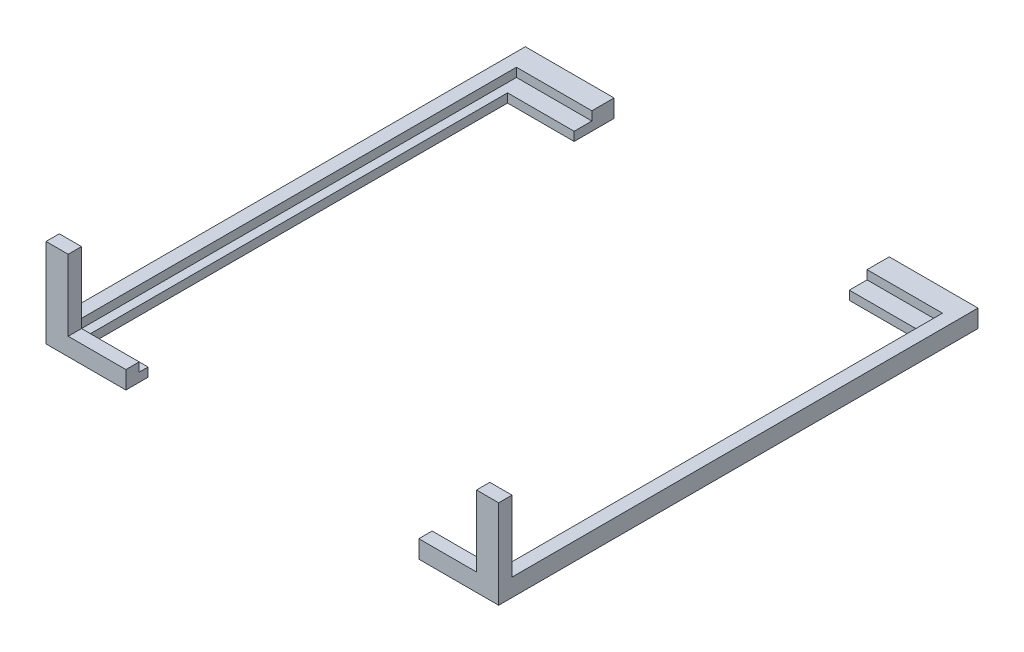
from build123d import *

# Parameters (mm, degrees)
SKETCH_1_W          = 51
SKETCH_1_H          = 54
EXTRUDE_1_DEPTH     = 10
SKETCH_2_W          = 46
SKETCH_2_H          = 47
CUT_EXTRUDE_1_DEPTH = 11
SKETCH_3_W          = 48
SKETCH_3_H          = 50
CUT_EXTRUDE_2_DEPTH = 9
SKETCH_4_W          = 31
SKETCH_4_H          = 4.5
CUT_EXTRUDE_3_DEPTH = 11
SKETCH_5_W          = 48
SKETCH_5_H          = 4.5
CUT_EXTRUDE_4_DEPTH = 8
SKETCH_6_W          = 1.5
SKETCH_6_H          = 52.5
CUT_EXTRUDE_5_DEPTH = 8
SKETCH_7_W          = 46
SKETCH_7_H          = 1.5
CUT_EXTRUDE_6_DEPTH = 8
SKETCH_8_W          = 33
SKETCH_8_H          = 5
CUT_EXTRUDE_7_DEPTH = 3


with BuildPart() as part:
    # 草图1 → 凸台-拉伸1 (new body)
    with BuildSketch(Plane(origin=(0, 0, 0), x_dir=(1, 0, 0), z_dir=(0, 1, 0))):
        Rectangle(SKETCH_1_W, SKETCH_1_H)
    extrude(amount=EXTRUDE_1_DEPTH)

    # 草图2 → 切除-拉伸1 (cut, through all)
    with BuildSketch(Plane(origin=(0, 10, 0), x_dir=(1, 0, 0), z_dir=(0, 1, 0))):
        with Locations((0, -1)):
            Rectangle(SKETCH_2_W, SKETCH_2_H)
    extrude(amount=-CUT_EXTRUDE_1_DEPTH, mode=Mode.SUBTRACT)

    # 草图3 → 切除-拉伸2 (cut)
    with BuildSketch(Plane(origin=(0, 10, 0), x_dir=(1, 0, 0), z_dir=(0, 1, 0))):
        with Locations((0, -0.5)):
            Rectangle(SKETCH_3_W, SKETCH_3_H)
    extrude(amount=-CUT_EXTRUDE_2_DEPTH, mode=Mode.SUBTRACT)

    # 草图4 → 切除-拉伸3 (cut, through all)
    with BuildSketch(Plane(origin=(0, 10, 0), x_dir=(1, 0, 0), z_dir=(0, 1, 0))):
        with Locations((0, 24.75)):
            Rectangle(SKETCH_4_W, SKETCH_4_H)
    extrude(amount=-CUT_EXTRUDE_3_DEPTH, mode=Mode.SUBTRACT)

    # 草图5 → 切除-拉伸4 (cut)
    with BuildSketch(Plane(origin=(0, 10, 0), x_dir=(1, 0, 0), z_dir=(0, 1, 0))):
        with Locations((0, 24.75)):
            Rectangle(SKETCH_5_W, SKETCH_5_H)
    extrude(amount=-CUT_EXTRUDE_4_DEPTH, mode=Mode.SUBTRACT)

    # 草图6 → 切除-拉伸5 (cut)
    with BuildSketch(Plane(origin=(0, 10, 0), x_dir=(1, 0, 0), z_dir=(0, 1, 0))):
        with Locations((-24.75, 0.75)):
            Rectangle(SKETCH_6_W, SKETCH_6_H)
        with Locations((24.75, 0.75)):
            Rectangle(SKETCH_6_W, SKETCH_6_H)
    extrude(amount=-CUT_EXTRUDE_5_DEPTH, mode=Mode.SUBTRACT)

    # 草图7 → 切除-拉伸6 (cut)
    with BuildSketch(Plane(origin=(0, 10, 0), x_dir=(1, 0, 0), z_dir=(0, 1, 0))):
        with Locations((0, -26.25)):
            Rectangle(SKETCH_7_W, SKETCH_7_H)
    extrude(amount=-CUT_EXTRUDE_6_DEPTH, mode=Mode.SUBTRACT)

    # 草图8 → 切除-拉伸7 (cut, through all)
    with BuildSketch(Plane(origin=(0, 2, 0), x_dir=(1, 0, 0), z_dir=(0, 1, 0))):
        with Locations((0, -27)):
            Rectangle(SKETCH_8_W, SKETCH_8_H)
    extrude(amount=-CUT_EXTRUDE_7_DEPTH, mode=Mode.SUBTRACT)


solid = part.part
